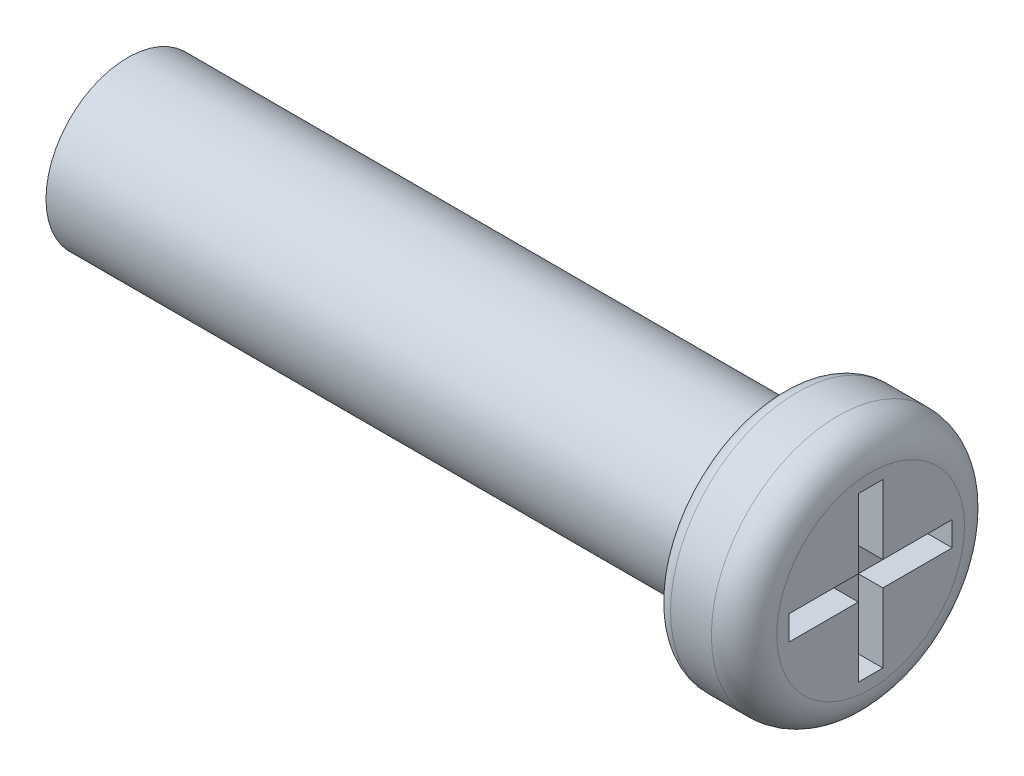
from build123d import *

# Parameters (mm, degrees)
ESBO_O1_R                = 1
RESSALTO_EXTRUS_O1_DEPTH = 25
ESBO_O2_R                = 1.55
RESSALTO_EXTRUS_O2_DEPTH = 1.1
SKETCH1_R                = 1
CUT_EXTRUDE1_DEPTH       = 17
SKETCH2_W                = 0.85
SKETCH2_H                = 0.3
SKETCH2_W_2              = 0.3
SKETCH2_H_2              = 0.85
CUT_EXTRUDE3_DEPTH       = 0.3
FILLET1_R                = 0.4
FILLET2_R                = 0.2


with BuildPart() as part:
    # Esboço1 → Ressalto-extrusão1 (new body)
    with BuildSketch(Plane(origin=(0, 0, 0), x_dir=(0, 0, -1), z_dir=(1, 0, 0))):
        Circle(ESBO_O1_R)
    extrude(amount=RESSALTO_EXTRUS_O1_DEPTH)

    # Esboço2 → Ressalto-extrusão2 (add)
    with BuildSketch(Plane(origin=(25, 0, 0), x_dir=(0, 0, -1), z_dir=(1, 0, 0))):
        Circle(ESBO_O2_R)
    extrude(amount=RESSALTO_EXTRUS_O2_DEPTH)

    # Sketch1 → Cut-Extrude1 (cut)
    with BuildSketch(Plane.ZY):
        Circle(SKETCH1_R)
    extrude(amount=-CUT_EXTRUDE1_DEPTH, mode=Mode.SUBTRACT)

    # Sketch2 → Cut-Extrude3 (cut)
    with BuildSketch(Plane(origin=(26.1, 0, 0), x_dir=(0, 0, -1), z_dir=(1, 0, 0))):
        with Locations((0.575, 0)):
            Rectangle(SKETCH2_W, SKETCH2_H)
        with Locations((-0.575, 0)):
            Rectangle(SKETCH2_W, SKETCH2_H)
        with Locations((0, 0.575)):
            Rectangle(SKETCH2_W_2, SKETCH2_H_2)
        with Locations((0, -0.575)):
            Rectangle(SKETCH2_W_2, SKETCH2_H_2)
        Rectangle(SKETCH2_W_2, SKETCH2_H)
    extrude(amount=-CUT_EXTRUDE3_DEPTH, mode=Mode.SUBTRACT)

    # Fillet1
    fillet1_edges = [part.edges().sort_by_distance(p)[0] for p in [
        (26.1, 0, 1.55),
    ]]
    fillet(fillet1_edges, radius=FILLET1_R)

    # Fillet2
    fillet2_edges = [part.edges().sort_by_distance(p)[0] for p in [
        (25, 0, 1.55),
    ]]
    fillet(fillet2_edges, radius=FILLET2_R)


solid = part.part
